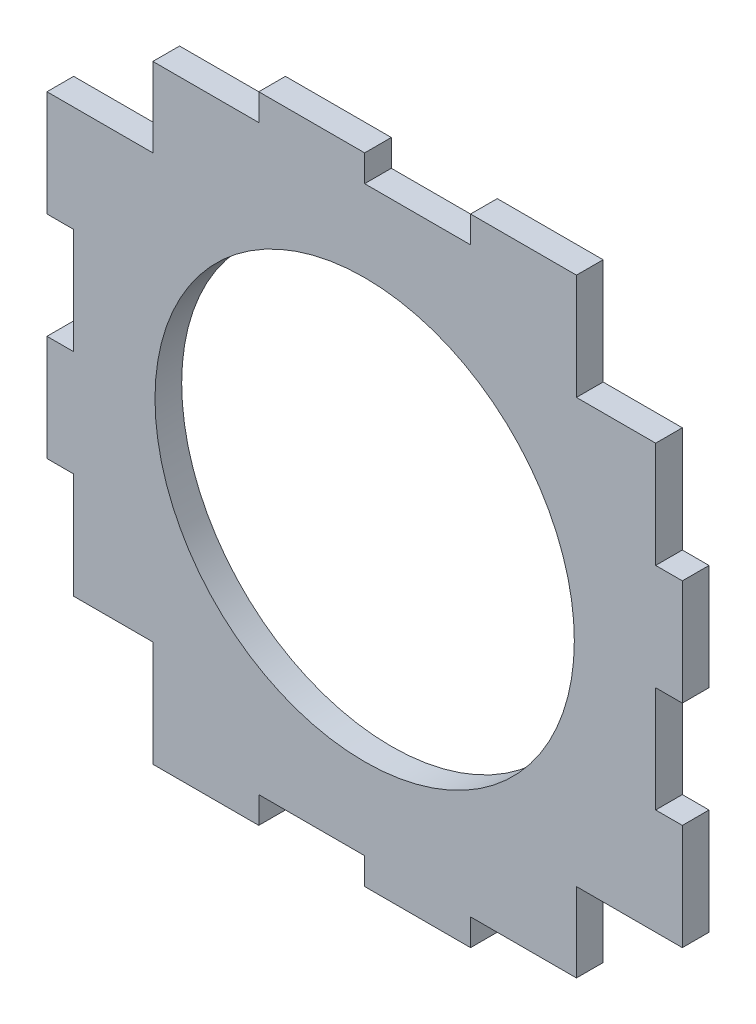
from build123d import *

# Parameters (mm, degrees)
SKETCH2_R           = 16.5
BOSS_EXTRUDE1_DEPTH = 2.1


with BuildPart() as part:
    # Sketch2 → Boss-Extrude1 (new body)
    with BuildSketch(Plane.XY):
        Polygon((-30, 11.666666667), (-21.666666667, 11.666666667), (-21.666666667, 17.9), (-13.333333333, 17.9), (-13.333333333, 20), (-5, 20), (-5, 17.9), (3.333333333, 17.9), (3.333333333, 20), (11.666666667, 20), (11.666666667, 11.666666667), (17.9, 11.666666667), (17.9, 3.333333333), (20, 3.333333333), (20, -5), (17.9, -5), (17.9, -13.333333333), (20, -13.333333333), (20, -21.666666667), (11.666666667, -21.666666667), (11.666666667, -27.9), (3.333333333, -27.9), (3.333333333, -30), (-5, -30), (-5, -27.9), (-13.333333333, -27.9), (-13.333333333, -30), (-21.666666667, -30), (-21.666666667, -21.666666667), (-27.9, -21.666666667), (-27.9, -13.333333333), (-30, -13.333333333), (-30, -5), (-27.9, -5), (-27.9, 3.333333333), (-30, 3.333333333), align=None)
        with Locations((-5, -5)):
            Circle(SKETCH2_R, mode=Mode.SUBTRACT)
    extrude(amount=BOSS_EXTRUDE1_DEPTH)


solid = part.part
